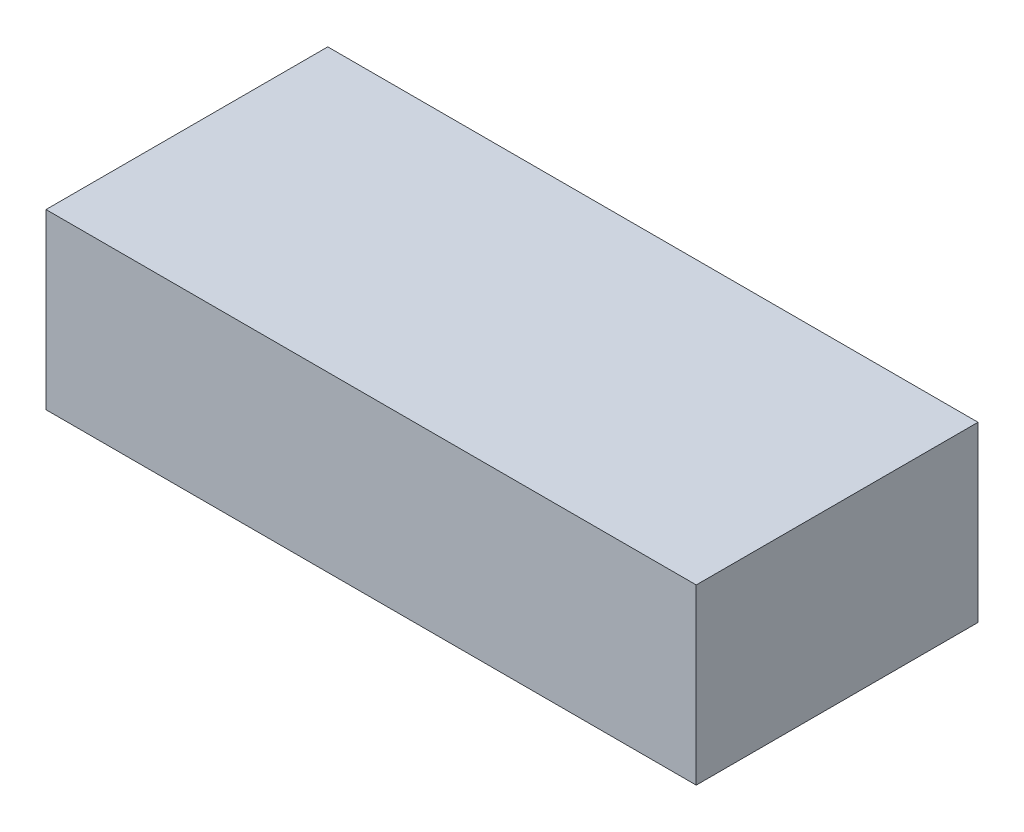
from build123d import *

# Parameters (mm, degrees)
SKETCH1_W           = 150
SKETCH1_H           = 65
BOSS_EXTRUDE1_DEPTH = 40
SKETCH2_W           = 143.904
SKETCH2_H           = 58.904
CUT_EXTRUDE1_DEPTH  = 28.4
SKETCH3_R           = 4
CUT_EXTRUDE2_DEPTH  = 3.048


with BuildPart() as part:
    # Sketch1 → Boss-Extrude1 (new body)
    with BuildSketch(Plane(origin=(0, 0, 0), x_dir=(1, 0, 0), z_dir=(0, 1, 0))):
        Rectangle(SKETCH1_W, SKETCH1_H)
    extrude(amount=BOSS_EXTRUDE1_DEPTH)

    # Sketch2 → Cut-Extrude1 (cut)
    with BuildSketch(Plane.XZ):
        Rectangle(SKETCH2_W, SKETCH2_H)
    extrude(amount=-CUT_EXTRUDE1_DEPTH, mode=Mode.SUBTRACT)

    # Sketch3 → Cut-Extrude2 (cut)
    with BuildSketch(Plane(origin=(0, 0, -32.5), x_dir=(-1, 0, 0), z_dir=(0, 0, -1))):
        with Locations((38.12, 12.19)):
            Circle(SKETCH3_R)
    extrude(amount=-CUT_EXTRUDE2_DEPTH, mode=Mode.SUBTRACT)


solid = part.part
